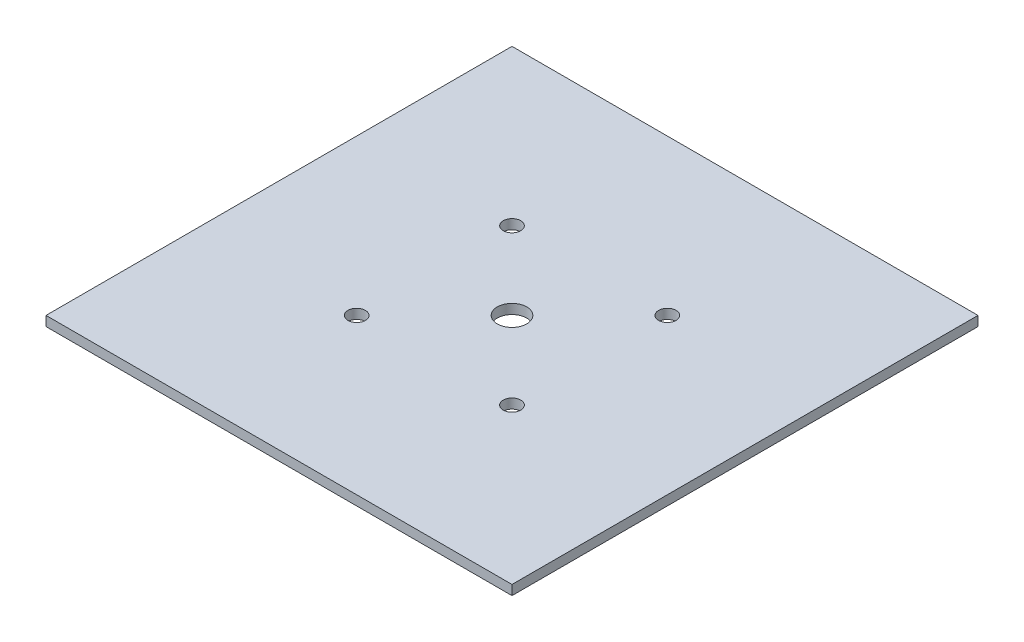
from build123d import *

# Parameters (mm, degrees)
SKETCH1_W           = 152.4
SKETCH1_H           = 3.175
BOSS_EXTRUDE1_DEPTH = 76.2
SKETCH2_R           = 2.8575
SKETCH2_R_2         = 4.826
CUT_EXTRUDE1_DEPTH  = 4.175


with BuildPart() as part:
    # Sketch1 → Boss-Extrude1 (new body, symmetric)
    with BuildSketch(Plane.XY):
        Rectangle(SKETCH1_W, SKETCH1_H)
    extrude(amount=BOSS_EXTRUDE1_DEPTH, both=True)

    # Sketch2 → Cut-Extrude1 (cut, through all)
    with BuildSketch(Plane(origin=(0, 1.5875, 0), x_dir=(1, 0, 0), z_dir=(0, 1, 0))):
        with Locations((-25.4, 25.4)):
            Circle(SKETCH2_R)
        with Locations((25.4, 25.4)):
            Circle(SKETCH2_R)
        with Locations((25.4, -25.4)):
            Circle(SKETCH2_R)
        with Locations((-25.4, -25.4)):
            Circle(SKETCH2_R)
        Circle(SKETCH2_R_2)
    extrude(amount=-CUT_EXTRUDE1_DEPTH, mode=Mode.SUBTRACT)


solid = part.part
